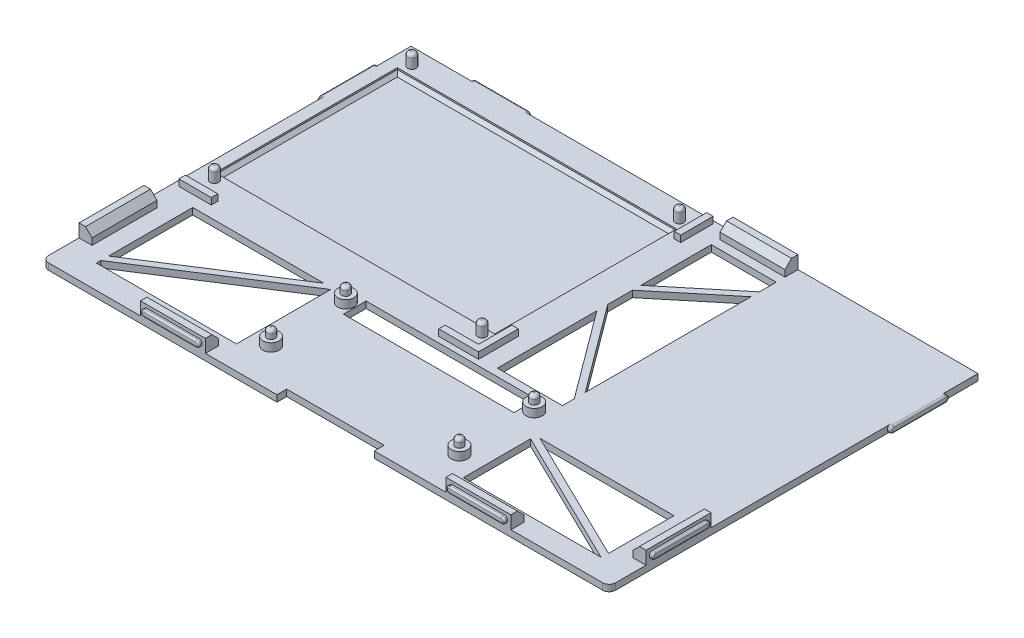
from build123d import *

# Parameters (mm, degrees)
SKETCH_1_W          = 174.55
SKETCH_1_H          = 113.55
EXTRUDE_1_DEPTH     = 2
SKETCH_3_W          = 2
SKETCH_3_H          = 10
SKETCH_3_W_2        = 10
SKETCH_3_H_2        = 2
EXTRUDE_2_DEPTH     = 2
SKETCH_4_R          = 1.3
EXTRUDE_3_DEPTH     = 4
FILLET_2_R          = 1
SKETCH_5_W          = 86
SKETCH_5_H          = 56
CUT_EXTRUDE_1_DEPTH = 1.5
SKETCH_8_R          = 2.5
EXTRUDE_4_DEPTH     = 2.5
SKETCH_8_3_R        = 1.25
EXTRUDE_5_DEPTH     = 5
FILLET_3_R          = 1
SKETCH_9_W          = 52.5
SKETCH_9_H          = 7
SKETCH_9_W_2        = 30
SKETCH_9_H_2        = 3
CUT_EXTRUDE_2_DEPTH = 2
SKETCH_10_W         = 20
SKETCH_10_H         = 4
SKETCH_10_W_2       = 4
SKETCH_10_H_2       = 20
EXTRUDE_6_DEPTH     = 4
CUT_EXTRUDE_3_DEPTH = 105.236875673
FILLET_1_R          = 2
CHAMFER_1_SIZE      = 2
EXTRUDE_8_DEPTH     = 1
EXTRUDE_9_DEPTH     = 1
EXTRUDE_11_DEPTH    = 1
EXTRUDE_START       = 1
EXTRUDE_12_DEPTH    = 1
BOSS_EXTRUDE1_DEPTH = 1
BOSS_EXTRUDE2_DEPTH = 1
FILLET_4_R          = 0.5
CHAMFER1_SIZE       = 1


with BuildPart() as part:
    # 草圖1 → 填料-伸長1 (new body)
    with BuildSketch(Plane(origin=(0, 0, 0), x_dir=(1, 0, 0), z_dir=(0, 1, 0))):
        Rectangle(SKETCH_1_W, SKETCH_1_H)
    extrude(amount=EXTRUDE_1_DEPTH)

    # 草圖3 → 填料-伸長2 (add)
    with BuildSketch(Plane(origin=(0, 2, 0), x_dir=(1, 0, 0), z_dir=(0, 1, 0))):
        with Locations((5.59, 50.93)):
            Rectangle(SKETCH_3_W, SKETCH_3_H)
        Polygon((4.59, -14.07), (4.59, -4.07), (6.59, -4.07), (6.59, -14.07), (6.59, -15.07), (6.59, -16.32), (-5.66, -16.32), (-5.66, -14.32), (4.59, -14.32), align=None)
        with Locations((-80.66, -15.32)):
            Rectangle(SKETCH_3_W_2, SKETCH_3_H_2)
    extrude(amount=EXTRUDE_2_DEPTH)

    # 草圖4 → 填料-伸長3 (add)
    with BuildSketch(Plane(origin=(0, 2, 0), x_dir=(1, 0, 0), z_dir=(0, 1, 0))):
        with Locations((0.54, 51.63)):
            Circle(SKETCH_4_R)
        with Locations((0.54, -9.17)):
            Circle(SKETCH_4_R)
        with Locations((-81.86, -9.17)):
            Circle(SKETCH_4_R)
        with Locations((-81.86, 51.63)):
            Circle(SKETCH_4_R)
    extrude(amount=EXTRUDE_3_DEPTH)

    # 圓角2
    fillet_2_edges = [part.edges().sort_by_distance(p)[0] for p in [
        (-83.16, 6, -51.63),
        (-83.16, 6, 9.17),
        (-0.76, 6, 9.17),
        (-0.76, 6, -51.63),
    ]]
    fillet(fillet_2_edges, radius=FILLET_2_R)

    # 草圖5 → 除料-伸長1 (cut)
    with BuildSketch(Plane(origin=(0, 2, 0), x_dir=(1, 0, 0), z_dir=(0, 1, 0))):
        with Locations((-40.66, 20.93)):
            Rectangle(SKETCH_5_W, SKETCH_5_H)
    extrude(amount=-CUT_EXTRUDE_1_DEPTH, mode=Mode.SUBTRACT)

    # 草圖8 → 填料-伸長4 (add)
    with BuildSketch(Plane(origin=(0, 2, 0), x_dir=(1, 0, 0), z_dir=(0, 1, 0))):
        with Locations((29, -21.575)):
            Circle(SKETCH_8_R)
        with Locations((29, -44.575)):
            Circle(SKETCH_8_R)
        with Locations((-29, -44.575)):
            Circle(SKETCH_8_R)
        with Locations((-29, -21.575)):
            Circle(SKETCH_8_R)
    extrude(amount=EXTRUDE_4_DEPTH)

    # 草圖8<3> → 填料-伸長5 (add)
    with BuildSketch(Plane(origin=(0, 2, 0), x_dir=(1, 0, 0), z_dir=(0, 1, 0))):
        with Locations((29, -21.575)):
            Circle(SKETCH_8_3_R)
        with Locations((29, -44.575)):
            Circle(SKETCH_8_3_R)
        with Locations((-29, -44.575)):
            Circle(SKETCH_8_3_R)
        with Locations((-29, -21.575)):
            Circle(SKETCH_8_3_R)
    extrude(amount=EXTRUDE_5_DEPTH)

    # 圓角3
    fillet_3_edges = [part.edges().sort_by_distance(p)[0] for p in [
        (-30.25, 7, 44.575),
        (27.75, 7, 44.575),
        (27.75, 7, 21.575),
        (-30.25, 7, 21.575),
    ]]
    fillet(fillet_3_edges, radius=FILLET_3_R)

    # 草圖9 → 除料-伸長2 (cut)
    with BuildSketch(Plane(origin=(0, 2, 0), x_dir=(1, 0, 0), z_dir=(0, 1, 0))):
        with Locations((0, -21.575)):
            Rectangle(SKETCH_9_W, SKETCH_9_H)
        with Locations((0, -55.275)):
            Rectangle(SKETCH_9_W_2, SKETCH_9_H_2)
    extrude(amount=-CUT_EXTRUDE_2_DEPTH, mode=Mode.SUBTRACT)

    # 草圖10 → 填料-伸長6 (add)
    with BuildSketch(Plane(origin=(0, 2, 0), x_dir=(1, 0, 0), z_dir=(0, 1, 0))):
        with Locations((21.854715439, 54.775)):
            Rectangle(SKETCH_10_W, SKETCH_10_H)
        with Locations((85.275, -35.43799868)):
            Rectangle(SKETCH_10_W_2, SKETCH_10_H_2)
        with Locations((47.031889085, -54.775)):
            Rectangle(SKETCH_10_W, SKETCH_10_H)
        with Locations((-47.031889085, -54.775)):
            Rectangle(SKETCH_10_W, SKETCH_10_H)
        with Locations((-85.275, -35.43799868)):
            Rectangle(SKETCH_10_W_2, SKETCH_10_H_2)
    extrude(amount=EXTRUDE_6_DEPTH)

    # 草圖11 → 除料-伸長3 (cut, through all)
    with BuildSketch(Plane(origin=(0, 2, 0), x_dir=(1, 0, 0), z_dir=(0, 1, 0))):
        Polygon((-77.879578173, -45.722583606), (-37.497069547, -19.823892626), (-77.879578173, -19.823892626), align=None)
        Polygon((-77.879578173, -49.467196386), (-34.764514275, -49.467196386), (-34.764514275, -20.447382192), (-77.879578173, -48.098554803), align=None)
        Polygon((31.854715439, 44.917489498), (11.854715439, 28.410289152), (11.854715439, 50.090728689), (31.854715439, 50.090728689), align=None)
        Polygon((11.854715439, -15.752914676), (31.854715439, -15.752914676), (31.854715439, -12.091582027), (11.854715439, 14.843632999), align=None)
        Polygon((11.854715439, 25.817052443), (31.854715439, 42.324252788), (31.854715439, -8.736726131), (11.854715439, 18.198488896), align=None)
        Polygon((78.359380095, -48.062791021), (37.115806701, -27.915068386), (78.359380095, -27.915068386), align=None)
        Polygon((35.80419089, -29.5002187), (35.80419089, -50.229107424), (78.237445455, -50.229107424), align=None)
    extrude(amount=-CUT_EXTRUDE_3_DEPTH, mode=Mode.SUBTRACT)

    # 圓角1
    fillet_1_edges = [part.edges().sort_by_distance(p)[0] for p in [
        (-87.275, 1, 56.775),
        (87.275, 1, 56.775),
    ]]
    fillet(fillet_1_edges, radius=FILLET_1_R)

    # 導角1
    chamfer_1_edges = [part.edges().sort_by_distance(p)[0] for p in [
        (83.275, 6, 35.43799868),
        (47.031889085, 6, 52.775),
        (-47.031889085, 6, 52.775),
        (21.854715439, 6, -52.775),
        (-83.275, 6, 35.43799868),
    ]]
    chamfer(chamfer_1_edges, length=CHAMFER_1_SIZE)

    # 草圖13 → 填料-伸長8 (add)
    with BuildSketch(Plane(origin=(87.275, 0, 0), x_dir=(0, 0, -1), z_dir=(1, 0, 0))):
        with BuildLine():
            Line((-43.43799868, 5), (-27.43799868, 5))
            ThreePointArc((-27.43799868, 5), (-26.43799868, 4), (-27.43799868, 3))
            Line((-27.43799868, 3), (-43.43799868, 3))
            ThreePointArc((-43.43799868, 3), (-44.43799868, 4), (-43.43799868, 5))
        make_face()
    extrude(amount=EXTRUDE_8_DEPTH)

    # 草圖14 → 填料-伸長9 (add)
    with BuildSketch(Plane(origin=(0, 0, -56.775), x_dir=(-1, 0, 0), z_dir=(0, 0, -1))):
        with BuildLine():
            Line((-29.854715439, 5), (-13.854715439, 5))
            ThreePointArc((-13.854715439, 5), (-12.854715439, 4), (-13.854715439, 3))
            Line((-13.854715439, 3), (-29.854715439, 3))
            ThreePointArc((-29.854715439, 3), (-30.854715439, 4), (-29.854715439, 5))
        make_face()
    extrude(amount=EXTRUDE_9_DEPTH)

    # 草圖15 → 填料-伸長11 (add)
    with BuildSketch(Plane.XY.offset(56.775)):
        with BuildLine():
            Line((-55.031889085, 5), (-39.031889085, 5))
            ThreePointArc((-39.031889085, 5), (-38.031889085, 4), (-39.031889085, 3))
            Line((-39.031889085, 3), (-55.031889085, 3))
            ThreePointArc((-55.031889085, 3), (-56.031889085, 4), (-55.031889085, 5))
        make_face()
        with BuildLine():
            Line((55.031889085, 5), (39.031889085, 5))
            ThreePointArc((39.031889085, 5), (38.031889085, 4), (39.031889085, 3))
            Line((39.031889085, 3), (55.031889085, 3))
            ThreePointArc((55.031889085, 3), (56.031889085, 4), (55.031889085, 5))
        make_face()
    extrude(amount=EXTRUDE_11_DEPTH)

    # 草圖16 → 填料-伸長12 (add)
    with BuildSketch(Plane.ZY.offset(87.275).offset(EXTRUDE_START)):
        with BuildLine():
            Line((27.43799868, 5), (43.43799868, 5))
            ThreePointArc((43.43799868, 5), (44.43799868, 4), (43.43799868, 3))
            Line((43.43799868, 3), (27.43799868, 3))
            ThreePointArc((27.43799868, 3), (26.43799868, 4), (27.43799868, 5))
        make_face()
    extrude(amount=-EXTRUDE_12_DEPTH)

    # Sketch1 → Boss-Extrude1 (add)
    with BuildSketch(Plane(origin=(0, 0, -56.775), x_dir=(-1, 0, 0), z_dir=(0, 0, -1))):
        with BuildLine():
            Line((68.15, 0), (52.15, 0))
            ThreePointArc((52.15, 0), (51.15, 1), (52.15, 2))
            Line((52.15, 2), (68.15, 2))
            ThreePointArc((68.15, 2), (69.15, 1), (68.15, 0))
        make_face()
    extrude(amount=BOSS_EXTRUDE1_DEPTH)

    # Sketch2 → Boss-Extrude2 (add)
    with BuildSketch(Plane(origin=(87.275, 0, 0), x_dir=(0, 0, -1), z_dir=(1, 0, 0))):
        with BuildLine():
            Line((29.84, 2), (45.84, 2))
            ThreePointArc((45.84, 2), (46.84, 1), (45.84, 0))
            Line((45.84, 0), (29.84, 0))
            ThreePointArc((29.84, 0), (28.84, 1), (29.84, 2))
        make_face()
    boss_extrude2 = extrude(amount=BOSS_EXTRUDE2_DEPTH)

    # Mirror1: Boss-Extrude2 across plane
    add(boss_extrude2.mirror(Plane.ZY))

    # 圓角4
    fillet_4_edges = [part.edges().sort_by_distance(p)[0] for p in [
        (12.854715439, 4, -57.775),
        (21.854715439, 3, -57.775),
        (30.854715439, 4, -57.775),
        (88.275, 4, 26.43799868),
        (88.275, 3, 35.43799868),
        (88.275, 4, 44.43799868),
        (56.031889085, 4, 57.775),
        (47.031889085, 3, 57.775),
        (38.031889085, 4, 57.775),
        (-88.275, 4, 44.43799868),
        (-88.275, 3, 35.43799868),
        (-88.275, 4, 26.43799868),
        (-38.031889085, 4, 57.775),
        (-47.031889085, 3, 57.775),
        (-56.031889085, 4, 57.775),
        (21.854715439, 5, -57.775),
        (88.275, 5, 35.43799868),
        (47.031889085, 5, 57.775),
        (-88.275, 5, 35.43799868),
        (-47.031889085, 5, 57.775),
        (-88.275, 1, -46.84),
        (-88.275, 0, -37.84),
        (-88.275, 1, -28.84),
        (88.275, 1, -46.84),
        (88.275, 0, -37.84),
        (88.275, 1, -28.84),
        (-69.15, 1, -57.775),
        (-60.15, 0, -57.775),
        (-51.15, 1, -57.775),
        (-88.275, 2, -37.84),
        (88.275, 2, -37.84),
        (-60.15, 2, -57.775),
    ]]
    fillet(fillet_4_edges, radius=FILLET_4_R)

    # Chamfer1
    chamfer1_edges = [part.edges().sort_by_distance(p)[0] for p in [
        (2.34, 0.5, -20.93),
        (-40.66, 0.5, 7.07),
        (-83.66, 0.5, -20.93),
        (-40.66, 0.5, -48.93),
    ]]
    chamfer(chamfer1_edges, length=CHAMFER1_SIZE)


solid = part.part
